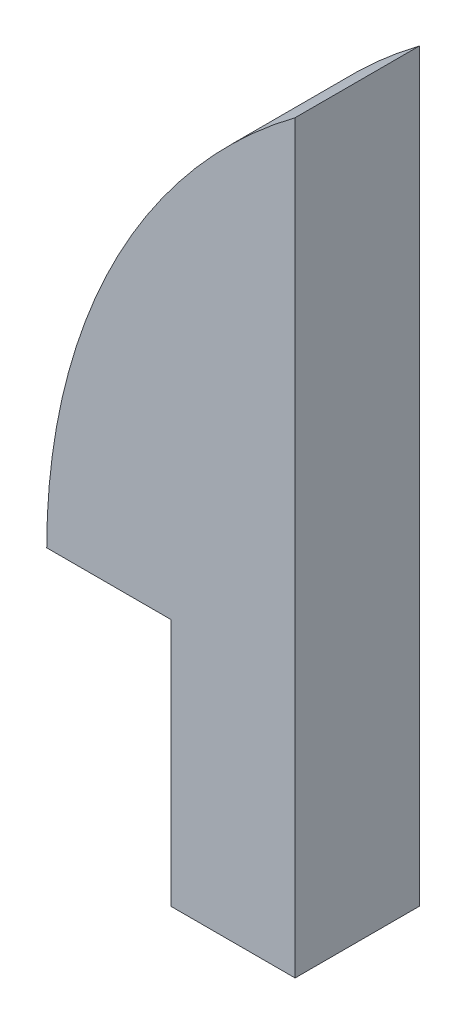
from build123d import *

# Parameters (mm, degrees)
BOSS_EXTRUDE1_DEPTH = 6.35


with BuildPart() as part:
    # Sketch1 → Boss-Extrude1 (new body)
    with BuildSketch(Plane.XY):
        with BuildLine():
            Line((6.35, 12.7), (6.35, 0))
            Line((6.35, 0), (12.7, 0))
            Line((12.7, 0), (12.7, 38.1))
            ThreePointArc((12.7, 38.1), (3.351936686, 26.899031657), (0, 12.7))
            Line((0, 12.7), (6.35, 12.7))
        make_face()
    extrude(amount=BOSS_EXTRUDE1_DEPTH)


solid = part.part
